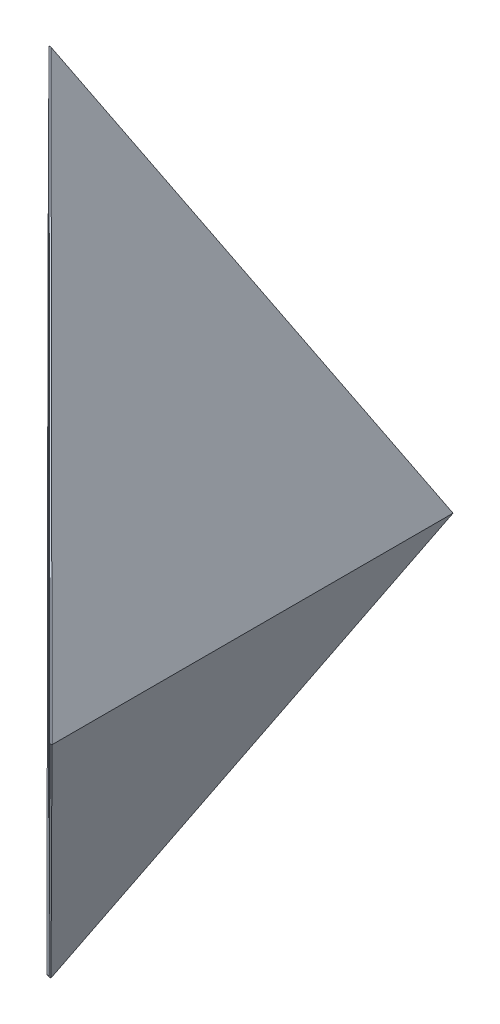
from build123d import *

# Parameters (mm, degrees)
DODANIE_WYCI_GNI_CIE1_DEPTH     = 20
WYTNIJ_WYCI_GNI_CIE2_DEPTH      = 10
WYTNIJ_WYCI_GNI_CIE2_DEPTH_BACK = 10
WYTNIJ_WYCI_GNI_CIE3_DEPTH      = 40


with BuildPart() as part:
    # Szkic2 → Dodanie-wyciągnięcie1 (new body)
    with BuildSketch(Plane.XY):
        Polygon((10, 0), (0, 20), (-10, 0), (0, -20), align=None)
    extrude(amount=DODANIE_WYCI_GNI_CIE1_DEPTH)

    # Szkic6 → Wytnij-wyciągnięcie2 (cut, two sides: drawn at the far end of the back side and taken through both)
    with BuildSketch(Plane(origin=(0, 0, 0), x_dir=(0, 0, -1), z_dir=(1, 0, 0)).offset(-WYTNIJ_WYCI_GNI_CIE2_DEPTH_BACK)):
        Polygon((-20, 0), (-20, 20), (0, 20), (0, -20), (-20, -20), align=None)
        Polygon((-10, 19.9), (-19.9, 0), (-10, -19.9), (-0.1, 0), align=None, mode=Mode.SUBTRACT)
    extrude(amount=WYTNIJ_WYCI_GNI_CIE2_DEPTH + WYTNIJ_WYCI_GNI_CIE2_DEPTH_BACK, mode=Mode.SUBTRACT)

    # Szkic7 → Wytnij-wyciągnięcie3 (cut)
    with BuildSketch(Plane(origin=(-5.024810608, 0, 5.05018844), x_dir=(-0.708885657709236, 0, -0.7053234182232602), z_dir=(0.7053234182232602, 0, -0.708885657709236))):
        Polygon((7.018324235, 0), (-7.017789899, 19.9), (-21.1247926, 0), (-7.088678465, -19.9), align=None)
    extrude(amount=-WYTNIJ_WYCI_GNI_CIE3_DEPTH, mode=Mode.SUBTRACT)


solid = part.part
